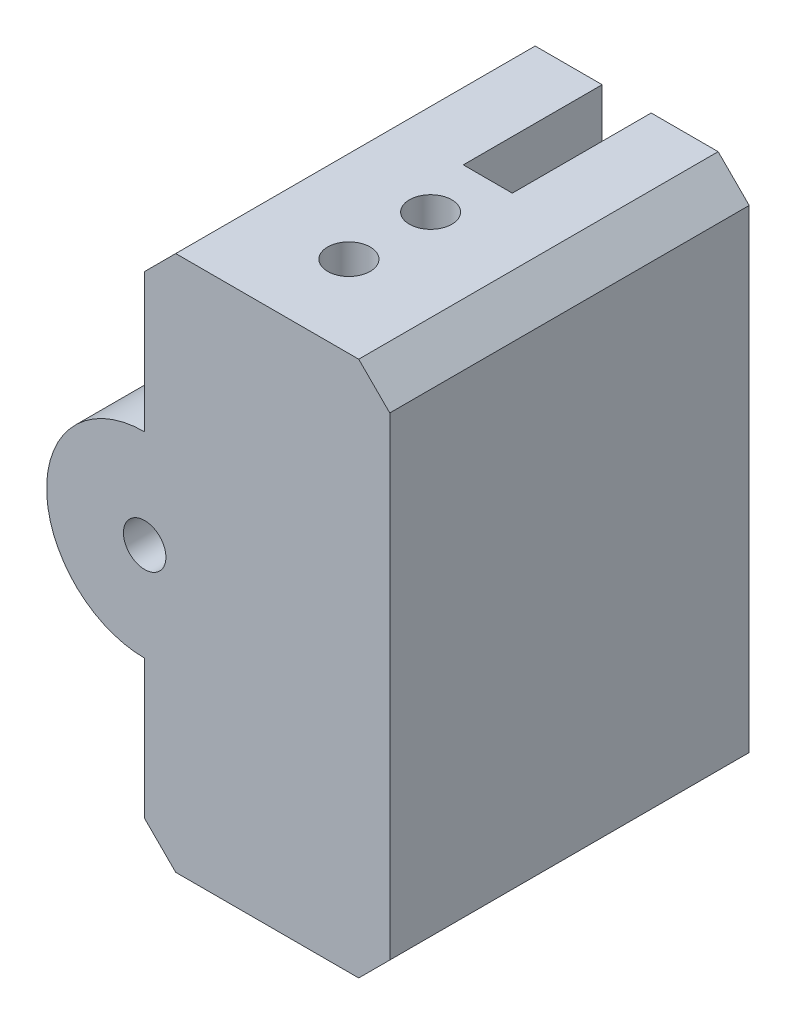
from build123d import *

# Parameters (mm, degrees)
SKETCH1_R               = 1.3
BOSS_EXTRUDE1_DEPTH     = 32.8
CHAMFER1_SIZE           = 1.9
CHAMFER2_SIZE           = 1.9
SKETCH2_R               = 6
BOSS_EXTRUDE2_DEPTH     = 22
SKETCH3_R               = 1.3
CUT_EXTRUDE1_DEPTH      = 1
CUT_EXTRUDE1_DEPTH_BACK = 23


with BuildPart() as part:
    # Sketch1 → Boss-Extrude1 (new body)
    with BuildSketch(Plane(origin=(0, 0, 0), x_dir=(1, 0, 0), z_dir=(0, 1, 0))):
        Polygon((-1.5, 0), (-7.5, 0), (-7.5, -22), (7.5, -22), (7.5, 0), (1.5, 0), (1.5, -8.5), (-1.5, -8.5), align=None)
        with Locations((0, -17)):
            Circle(SKETCH1_R, mode=Mode.SUBTRACT)
        with Locations((0, -12)):
            Circle(SKETCH1_R, mode=Mode.SUBTRACT)
    extrude(amount=BOSS_EXTRUDE1_DEPTH)

    # Chamfer1
    chamfer1_edges = [part.edges().sort_by_distance(p)[0] for p in [
        (7.5, 0, 11),
        (7.5, 32.8, 11),
    ]]
    chamfer(chamfer1_edges, length=CHAMFER1_SIZE)

    # Chamfer2
    chamfer2_edges = [part.edges().sort_by_distance(p)[0] for p in [
        (-7.5, 0, 11),
        (-7.5, 32.8, 11),
    ]]
    chamfer(chamfer2_edges, length=CHAMFER2_SIZE)

    # Sketch2 → Boss-Extrude2 (add)
    with BuildSketch(Plane(origin=(0, 0, 0), x_dir=(-1, 0, 0), z_dir=(0, 0, -1))):
        with Locations((7.5, 16.4)):
            Circle(SKETCH2_R)
    extrude(amount=-BOSS_EXTRUDE2_DEPTH)

    # Sketch3 → Cut-Extrude1 (cut, two sides)
    with BuildSketch(Plane(origin=(0, 0, 0), x_dir=(-1, 0, 0), z_dir=(0, 0, -1))) as cut_extrude1_sk:
        with Locations((7.5, 16.4)):
            Circle(SKETCH3_R)
    extrude(amount=CUT_EXTRUDE1_DEPTH, mode=Mode.SUBTRACT)
    extrude(cut_extrude1_sk.sketch, amount=-CUT_EXTRUDE1_DEPTH_BACK, mode=Mode.SUBTRACT)


solid = part.part
